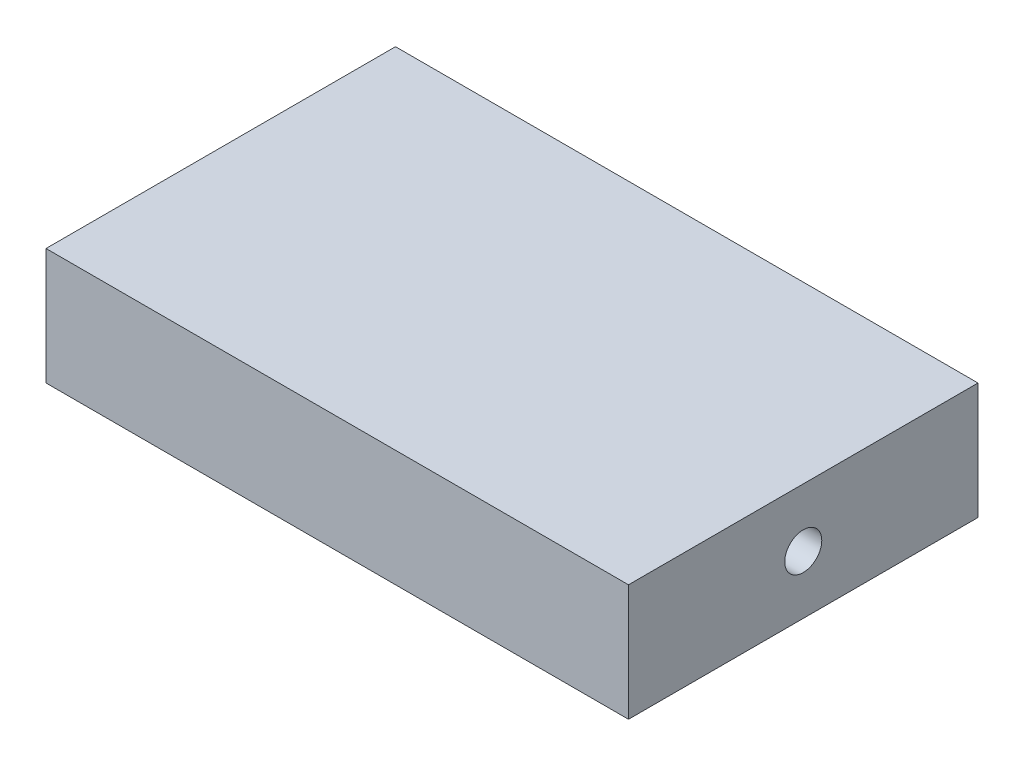
from build123d import *

# Parameters (mm, degrees)
SKETCH1_W           = 63.5
SKETCH1_H           = 38.1
BOSS_EXTRUDE1_DEPTH = 12.7


with BuildPart() as part:
    # Sketch1 → Boss-Extrude1 (new body)
    with BuildSketch(Plane(origin=(0, 0, 0), x_dir=(1, 0, 0), z_dir=(0, 1, 0))):
        Rectangle(SKETCH1_W, SKETCH1_H)
    extrude(amount=BOSS_EXTRUDE1_DEPTH)

    # Sketch5 → #10-32 Tapped Hole1 (revolve, cut)
    with BuildSketch(Plane(origin=(-31.75, 6.35, 0), x_dir=(0, 0, 1), z_dir=(0, 1, 0))):
        Polygon((0, 0), (0, 13.151317848), (2.0193, 11.938), (2.0193, 0), align=None)
    f_10_32_tapped_hole1 = revolve(axis=Axis((-38.1, 6.35, 0), (1, 0, 0)), mode=Mode.SUBTRACT)

    # Mirror1: #10-32 Tapped Hole1 across plane
    add(f_10_32_tapped_hole1.mirror(Plane(origin=(0, 0, 0), x_dir=(0, 0, 1), z_dir=(1, 0, 0))), mode=Mode.SUBTRACT)


solid = part.part
